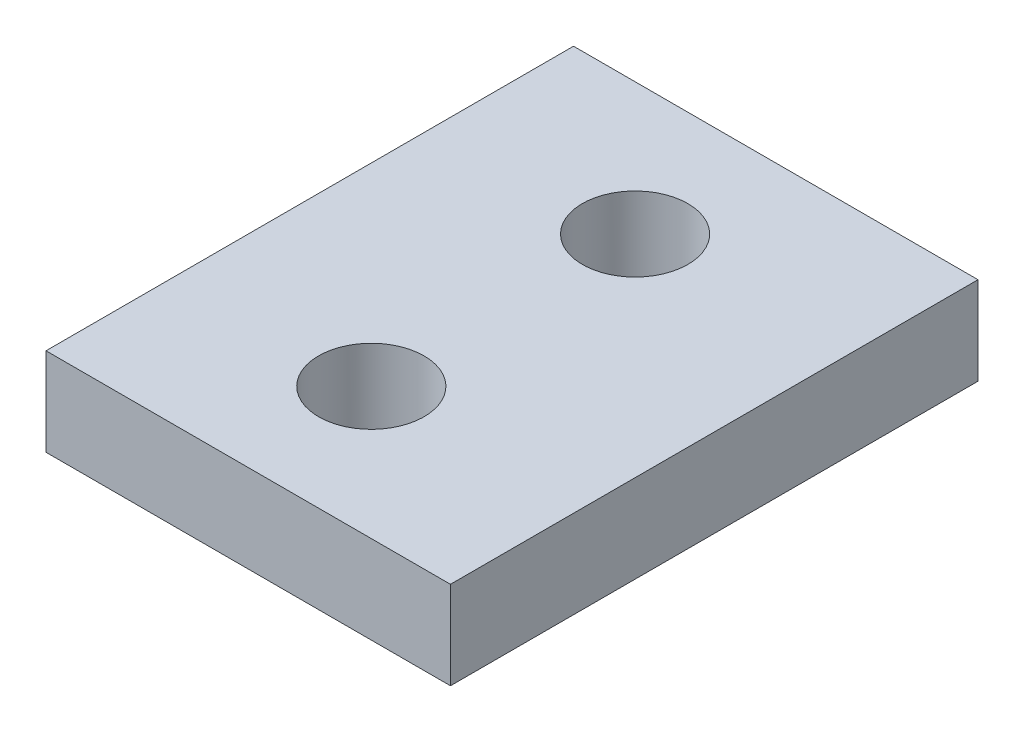
from build123d import *

# Parameters (mm, degrees)
SKIZZE4_W                            = 23
SKIZZE4_H                            = 5
AUFSATZ_LINEAR_AUSTRAGEN1_DEPTH      = 15
AUFSATZ_LINEAR_AUSTRAGEN1_DEPTH_BACK = 15
SKIZZE6_R                            = 3
SCHNITT_LINEAR_AUSTRAGEN1_DEPTH      = 16


with BuildPart() as part:
    # Skizze4 → Aufsatz-Linear austragen1 (new body, two sides)
    with BuildSketch(Plane.XY) as aufsatz_linear_austragen1_sk:
        with Locations((53.5, 13.5)):
            Rectangle(SKIZZE4_W, SKIZZE4_H)
    extrude(amount=AUFSATZ_LINEAR_AUSTRAGEN1_DEPTH)
    extrude(aufsatz_linear_austragen1_sk.sketch, amount=-AUFSATZ_LINEAR_AUSTRAGEN1_DEPTH_BACK)

    # Skizze6 → Schnitt-Linear austragen1 (cut)
    with BuildSketch(Plane(origin=(0, 0, 0), x_dir=(1, 0, 0), z_dir=(0, 1, 0))):
        with Locations((53, 7.5)):
            Circle(SKIZZE6_R)
        with Locations((53, -7.5)):
            Circle(SKIZZE6_R)
    extrude(amount=SCHNITT_LINEAR_AUSTRAGEN1_DEPTH, mode=Mode.SUBTRACT)


solid = part.part
